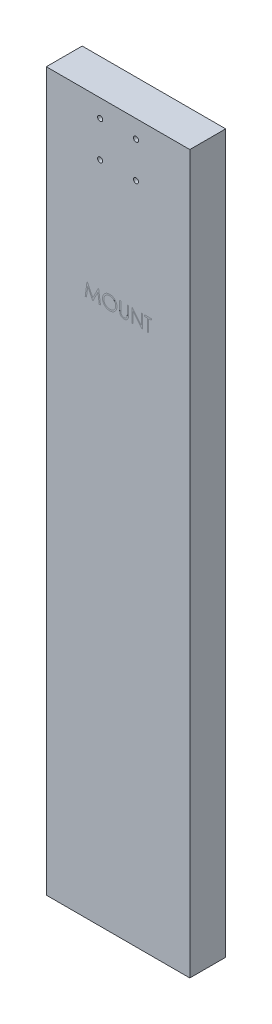
from build123d import *

# Parameters (mm, degrees)
SKETCH1_W                = 200
SKETCH1_H                = 1000
BOSS_EXTRUDE1_DEPTH      = 50
CUT_EXTRUDE1_DEPTH       = 0.005
M6_CLEARANCE_HOLE1_D     = 7
M6_CLEARANCE_HOLE1_DEPTH = 50


with BuildPart() as part:
    # Sketch1 → Boss-Extrude1 (new body)
    with BuildSketch(Plane.XY):
        with Locations((100, 500)):
            Rectangle(SKETCH1_W, SKETCH1_H)
    extrude(amount=BOSS_EXTRUDE1_DEPTH)

    # Sketch2 → Cut-Extrude1 (cut)
    with BuildSketch(Plane.XY.offset(50)):
        Polygon((54.206730769, 750), (56.721544471, 769.05), (56.96577524, 769.05), (64.830769231, 753.419230769), (72.676682692, 769.05), (72.924729567, 769.05), (75.454807692, 750), (73.737560096, 750), (71.913461538, 763.707451923), (65.036838942, 750), (64.65141226, 750), (57.748076923, 763.737980769), (55.927794471, 750), align=None)
        with BuildLine():
            add(Edge.make_bspline(
                [(88.276923077, 769.538461538), (88.629664339, 769.529527201), (89.322477281, 769.511979424), (90.340699224, 769.377654589), (91.312766814, 769.145269681), (92.24659857, 768.835772591), (93.131024628, 768.422908007), (93.972702028, 767.923878843), (94.769628156, 767.333456974), (95.511061675, 766.656206468), (96.189551648, 765.919333669), (96.787318257, 765.132961044), (97.288291313, 764.301843278), (97.699693955, 763.428477899), (98.022447816, 762.514840074), (98.245164325, 761.556059002), (98.387430542, 760.558346874), (98.404062702, 759.87784351), (98.4125, 759.532632212)],
                knots=[0, 0, 0, 0, 0.001058053, 0.002078103, 0.00307407, 0.004052758, 0.005024255, 0.005996134, 0.006983761, 0.007994128, 0.009004251, 0.009984998, 0.010952288, 0.011909956, 0.012876697, 0.013853217, 0.014858651, 0.015893829, 0.015893829, 0.015893829, 0.015893829], degree=3))
            add(Edge.make_bspline(
                [(98.4125, 759.532632212), (98.404063939, 759.189963825), (98.387435485, 758.514524737), (98.245002567, 757.52314399), (98.021622267, 756.570150342), (97.702691161, 755.657134718), (97.293249628, 754.783133978), (96.788940768, 753.950447843), (96.19490075, 753.158803331), (95.518860603, 752.416872967), (94.781892075, 751.736529591), (93.99142448, 751.143699711), (93.165235124, 750.633572689), (92.292692284, 750.226535835), (91.385367798, 749.901205811), (90.435141154, 749.679395068), (89.446464909, 749.536318447), (88.772252732, 749.519889096), (88.429567308, 749.511538462)],
                knots=[0, 0, 0, 0, 0.001027553, 0.002025427, 0.002998234, 0.003960113, 0.004921233, 0.005888524, 0.006875369, 0.007885737, 0.008895859, 0.009879653, 0.010845663, 0.01180333, 0.012762874, 0.01373197, 0.014726064, 0.015753617, 0.015753617, 0.015753617, 0.015753617], degree=3))
            add(Edge.make_bspline(
                [(88.429567308, 749.511538462), (88.0843578, 749.519971553), (87.403857968, 749.536595421), (86.404892104, 749.679097067), (85.445437526, 749.901934735), (84.528237986, 750.220393237), (83.652782012, 750.631967022), (82.817357419, 751.133822285), (82.025317489, 751.729309725), (81.283228841, 752.405130652), (80.604236776, 753.1408501), (80.012275031, 753.929162259), (79.510306915, 754.754601245), (79.100115062, 755.619457769), (78.775369933, 756.519550907), (78.553819423, 757.460884763), (78.410476598, 758.438092645), (78.393958362, 759.103443277), (78.385576923, 759.441045673)],
                knots=[0, 0, 0, 0, 0.001035178, 0.002040611, 0.003020846, 0.003986328, 0.004947449, 0.005918008, 0.006904854, 0.007915221, 0.008925344, 0.009903794, 0.010867819, 0.011818589, 0.012770942, 0.013732616, 0.014715373, 0.015727677, 0.015727677, 0.015727677, 0.015727677], degree=3))
            add(Edge.make_bspline(
                [(78.385576923, 759.441045673), (78.388486868, 759.667646344), (78.394270047, 760.117989016), (78.463893402, 760.786734368), (78.56492209, 761.444724948), (78.709712499, 762.090089679), (78.899078572, 762.721248753), (79.122518893, 763.342555048), (79.395422908, 763.947712173), (79.703927578, 764.539586919), (80.048252562, 765.108952807), (80.428576284, 765.647140252), (80.831540218, 766.158665392), (81.273300975, 766.630272656), (81.739299055, 767.075681557), (82.237093942, 767.488047202), (82.763648158, 767.871088007), (83.321227396, 768.216275863), (83.896092578, 768.528473439), (84.488693326, 768.796380942), (85.090981236, 769.02632022), (85.705777249, 769.21268814), (86.331448765, 769.35981965), (86.969361335, 769.460008247), (87.619006756, 769.529809177), (88.056674077, 769.535565009), (88.276923077, 769.538461538)],
                knots=[0, 0, 0, 0, 0.000679535, 0.001350497, 0.002014905, 0.002675929, 0.003332765, 0.003990697, 0.004655204, 0.005322597, 0.005992114, 0.006649571, 0.007298589, 0.007943963, 0.008586385, 0.00923134, 0.009881692, 0.010538207, 0.011197278, 0.011842821, 0.012487777, 0.013129994, 0.013768699, 0.014414264, 0.015066238, 0.0157267, 0.0157267, 0.0157267, 0.0157267], degree=3))
        make_face()
        with BuildLine():
            add(Edge.make_bspline(
                [(88.360877404, 767.584615385), (88.180094898, 767.582411625), (87.820258181, 767.578025173), (87.28530949, 767.52024535), (86.757396251, 767.437895526), (86.236409436, 767.320430391), (85.724528919, 767.160388333), (85.216983354, 766.976197104), (84.718401018, 766.751836596), (84.230427878, 766.49834802), (83.75736154, 766.217774608), (83.310978122, 765.907685419), (82.890122017, 765.575352431), (82.495823666, 765.220000059), (82.129240857, 764.839818655), (81.783158411, 764.440571824), (81.471448259, 764.01084796), (81.185776763, 763.562299888), (80.930137518, 763.095511853), (80.702814658, 762.615398174), (80.516864839, 762.118042479), (80.365213905, 761.608840564), (80.239484935, 761.088598891), (80.159834577, 760.553370914), (80.101419877, 760.00584609), (80.097284147, 759.63583057), (80.095192308, 759.448677885)],
                knots=[0, 0, 0, 0, 0.000542102, 0.001079021, 0.001612294, 0.002144596, 0.002679355, 0.003220247, 0.003763476, 0.004318191, 0.004869245, 0.005412287, 0.005947481, 0.006477054, 0.007003304, 0.007531045, 0.008060756, 0.008594315, 0.009125467, 0.009656399, 0.010186564, 0.010716563, 0.011249726, 0.011790537, 0.012338849, 0.012900025, 0.012900025, 0.012900025, 0.012900025], degree=3))
            add(Edge.make_bspline(
                [(80.095192308, 759.448677885), (80.102131199, 759.17347494), (80.115782145, 758.632065611), (80.235294063, 757.838670428), (80.419382238, 757.076189898), (80.690748761, 756.348796077), (81.030114249, 755.650236481), (81.449360609, 754.986708082), (81.946070775, 754.358031552), (82.510296541, 753.768595874), (83.127095844, 753.230592282), (83.782049703, 752.758351444), (84.468141481, 752.358789941), (85.187160341, 752.033279476), (85.935267661, 751.775343903), (86.717284046, 751.598567353), (87.528000119, 751.482223803), (88.08061697, 751.471050946), (88.360877404, 751.465384615)],
                knots=[0, 0, 0, 0, 0.000825162, 0.001623348, 0.002401731, 0.003174434, 0.00394756, 0.004727858, 0.005524108, 0.006347335, 0.007172294, 0.007976126, 0.008766133, 0.009550007, 0.010340456, 0.011135618, 0.011952166, 0.012792412, 0.012792412, 0.012792412, 0.012792412], degree=3))
            add(Edge.make_bspline(
                [(88.360877404, 751.465384615), (88.549251977, 751.467972718), (88.922855332, 751.473105702), (89.478546675, 751.524805643), (90.024226913, 751.607710532), (90.559130665, 751.727075958), (91.082650853, 751.876467181), (91.596972567, 752.053946386), (92.096617547, 752.275368366), (92.58788895, 752.520013646), (93.058131351, 752.798906503), (93.507033891, 753.098471289), (93.923281724, 753.430314782), (94.317285099, 753.780387447), (94.685372949, 754.155747819), (95.025056135, 754.555907884), (95.335190854, 754.983393461), (95.620753873, 755.431261169), (95.875497346, 755.899326488), (96.097452157, 756.381180878), (96.285753873, 756.87563783), (96.437764735, 757.383410526), (96.556884176, 757.903534575), (96.638962026, 758.4367064), (96.696375671, 758.981859393), (96.700703162, 759.350579523), (96.702884615, 759.536448317)],
                knots=[0, 0, 0, 0, 0.00056499, 0.001120545, 0.001672668, 0.002219864, 0.002763441, 0.003305341, 0.003850524, 0.004401763, 0.004950871, 0.005489605, 0.006019439, 0.006546463, 0.007069979, 0.007595245, 0.008119623, 0.008653182, 0.009187682, 0.009717008, 0.010243603, 0.010773602, 0.011305904, 0.011842946, 0.012391258, 0.012948618, 0.012948618, 0.012948618, 0.012948618], degree=3))
            add(Edge.make_bspline(
                [(96.702884615, 759.536448317), (96.700701415, 759.721045562), (96.696370634, 760.087228201), (96.638989451, 760.628579226), (96.556797462, 761.157914563), (96.438346151, 761.673156119), (96.285673171, 762.174435234), (96.097419273, 762.661281104), (95.875430714, 763.135507423), (95.620660236, 763.595942097), (95.334279825, 764.037764599), (95.021346873, 764.460143445), (94.676458335, 764.855146508), (94.309468114, 765.232525343), (93.911209438, 765.584231285), (93.483486351, 765.910381004), (93.031491477, 766.21884554), (92.552916095, 766.497114669), (92.059009719, 766.754094993), (91.552203747, 766.974264025), (91.038239648, 767.16134656), (90.518424408, 767.320914613), (89.988382769, 767.437435463), (89.451696215, 767.520319563), (88.909107264, 767.578005063), (88.544200597, 767.582404952), (88.360877404, 767.584615385)],
                knots=[0, 0, 0, 0, 0.000553546, 0.00109806, 0.001631333, 0.002159915, 0.00268261, 0.003202077, 0.00372448, 0.00425229, 0.004779424, 0.005302996, 0.005827846, 0.006351362, 0.006881238, 0.007420106, 0.007964139, 0.008521761, 0.009079865, 0.009633569, 0.010178043, 0.010720105, 0.011263575, 0.011804386, 0.012348901, 0.012898632, 0.012898632, 0.012898632, 0.012898632], degree=3))
        make_face(mode=Mode.SUBTRACT)
        with BuildLine():
            Line((102.320192308, 769.05), (104.029807692, 769.05))
            Line((104.029807692, 769.05), (104.029807692, 757.636027644))
            add(Edge.make_bspline(
                [(104.029807692, 757.636027644), (104.029553272, 757.47447964), (104.029070464, 757.167914462), (104.032295433, 756.731569854), (104.041327138, 756.343644041), (104.047021235, 756.002641707), (104.059688579, 755.71012761), (104.070019377, 755.46451699), (104.083302978, 755.266972831), (104.099267518, 755.151688077), (104.106129808, 755.102133413)],
                knots=[0, 0, 0, 0, 0.000484645, 0.000919698, 0.001309016, 0.001648735, 0.001942798, 0.002187297, 0.002386321, 0.002536367, 0.002536367, 0.002536367, 0.002536367], degree=3))
            add(Edge.make_bspline(
                [(104.106129808, 755.102133413), (104.134309976, 754.923353173), (104.189082462, 754.575866319), (104.328672032, 754.081065527), (104.523621574, 753.635124305), (104.754632992, 753.224127134), (105.059066205, 752.859513618), (105.423756876, 752.523625907), (105.865595873, 752.229865085), (106.356871455, 751.961255666), (106.886381105, 751.745364289), (107.427462426, 751.582114692), (107.97198207, 751.482625252), (108.336523768, 751.471105233), (108.517548077, 751.465384615)],
                knots=[0, 0, 0, 0, 0.000542706, 0.001054833, 0.001536872, 0.002000273, 0.002463973, 0.002955555, 0.003482676, 0.004051288, 0.004633103, 0.005194538, 0.005744759, 0.006287505, 0.006287505, 0.006287505, 0.006287505], degree=3))
            add(Edge.make_bspline(
                [(108.517548077, 751.465384615), (108.672962007, 751.471229429), (108.982892237, 751.482885298), (109.443392952, 751.555065373), (109.891884972, 751.685152738), (110.330582958, 751.853009137), (110.741796174, 752.074792454), (111.125754051, 752.330992309), (111.46845775, 752.63149722), (111.781193424, 752.964057667), (112.053526432, 753.339287149), (112.28958936, 753.749015301), (112.48295192, 754.199408174), (112.578438819, 754.515934387), (112.62749399, 754.678545673)],
                knots=[0, 0, 0, 0, 0.000466331, 0.000929968, 0.001393872, 0.001865126, 0.002336303, 0.002792484, 0.003246969, 0.003700588, 0.004159315, 0.004634539, 0.005116578, 0.005625853, 0.005625853, 0.005625853, 0.005625853], degree=3))
            add(Edge.make_bspline(
                [(112.62749399, 754.678545673), (112.643823244, 754.745757199), (112.680211401, 754.895531565), (112.714213174, 755.148740304), (112.749627263, 755.447495271), (112.774199422, 755.793942995), (112.798154636, 756.186922574), (112.812486075, 756.628481204), (112.819110212, 757.117015519), (112.821084229, 757.457940643), (112.822115385, 757.636027644)],
                knots=[0, 0, 0, 0, 0.000207373, 0.000462111, 0.000765533, 0.00111002, 0.001503745, 0.001946676, 0.002435197, 0.002969466, 0.002969466, 0.002969466, 0.002969466], degree=3))
            Line((112.822115385, 757.636027644), (112.822115385, 769.05))
            Line((112.822115385, 769.05), (114.531730769, 769.05))
            Line((114.531730769, 769.05), (114.531730769, 757.544441106))
            add(Edge.make_bspline(
                [(114.531730769, 757.544441106), (114.530347628, 757.337077072), (114.527648345, 756.932393552), (114.504240921, 756.339386869), (114.46691925, 755.776851356), (114.414188372, 755.244711397), (114.344318397, 754.744871187), (114.266620411, 754.27294952), (114.16767181, 753.832333946), (114.052101441, 753.41958893), (113.919983986, 753.026693493), (113.748854308, 752.65381089), (113.556043815, 752.289605372), (113.327364061, 751.939585522), (113.07039925, 751.602201569), (112.779469388, 751.279499603), (112.464196455, 750.966322794), (112.119339423, 750.670704534), (111.750582993, 750.399603022), (111.359024081, 750.16121801), (110.94767052, 749.95970375), (110.51759159, 749.793827647), (110.068603757, 749.669106757), (109.600695699, 749.576169123), (109.112802376, 749.523360904), (108.780980461, 749.515512684), (108.612950721, 749.511538462)],
                knots=[0, 0, 0, 0, 0.000622072, 0.001214011, 0.001780083, 0.002313205, 0.002817812, 0.003293985, 0.003747637, 0.004171705, 0.004579618, 0.004989561, 0.005401029, 0.005814896, 0.006242317, 0.006672048, 0.007117291, 0.007574667, 0.008033394, 0.008488904, 0.008947996, 0.009405817, 0.009869721, 0.010344209, 0.010835584, 0.011339671, 0.011339671, 0.011339671, 0.011339671], degree=3))
            add(Edge.make_bspline(
                [(108.612950721, 749.511538462), (108.429694606, 749.515809827), (108.070146762, 749.52419023), (107.540349567, 749.572211199), (107.032453728, 749.662662745), (106.541095025, 749.777833296), (106.072963063, 749.936676209), (105.621785887, 750.122267431), (105.195290779, 750.350199376), (104.786558722, 750.603800558), (104.406512549, 750.889140375), (104.057639541, 751.200146179), (103.739363731, 751.531835947), (103.457049827, 751.887800795), (103.206020441, 752.265272229), (102.989774565, 752.665318091), (102.80410105, 753.087783498), (102.708271021, 753.38144306), (102.659825721, 753.529897837)],
                knots=[0, 0, 0, 0, 0.00054985, 0.001078804, 0.00159388, 0.002096463, 0.002591234, 0.003075293, 0.003558373, 0.00404014, 0.004517154, 0.004982061, 0.005440915, 0.005894454, 0.006343216, 0.006799141, 0.007257137, 0.007725384, 0.007725384, 0.007725384, 0.007725384], degree=3))
            add(Edge.make_bspline(
                [(102.659825721, 753.529897837), (102.631647189, 753.631312277), (102.570527325, 753.851282458), (102.505075347, 754.21533606), (102.45005306, 754.634517255), (102.398315665, 755.108854735), (102.367786908, 755.638716152), (102.341021992, 756.223871822), (102.320003752, 756.8650293), (102.320127699, 757.311640306), (102.320192308, 757.544441106)],
                knots=[0, 0, 0, 0, 0.000315631, 0.000684612, 0.001108268, 0.001584059, 0.002115608, 0.002700083, 0.003341473, 0.00403983, 0.00403983, 0.00403983, 0.00403983], degree=3))
            Line((102.320192308, 757.544441106), (102.320192308, 769.05))
        make_face()
        Polygon((119.416346154, 750), (119.416346154, 769.05), (119.775060096, 769.05), (132.360576923, 754.056520433), (132.360576923, 769.05), (134.070192308, 769.05), (134.070192308, 750), (133.680949519, 750), (121.125961538, 764.959134615), (121.125961538, 750), align=None)
        Polygon((136.756730769, 767.096153846), (136.756730769, 769.05), (146.770192308, 769.05), (146.770192308, 767.096153846), (142.618269231, 767.096153846), (142.618269231, 750), (140.908653846, 750), (140.908653846, 767.096153846), align=None)
    extrude(amount=-CUT_EXTRUDE1_DEPTH, mode=Mode.SUBTRACT)

    # M6 Clearance Hole1
    with Locations(Plane.XY.offset(50)):
        with Locations((75, 975), (125, 975), (125, 925), (75, 925)):
            Hole(M6_CLEARANCE_HOLE1_D / 2, depth=M6_CLEARANCE_HOLE1_DEPTH)


solid = part.part
